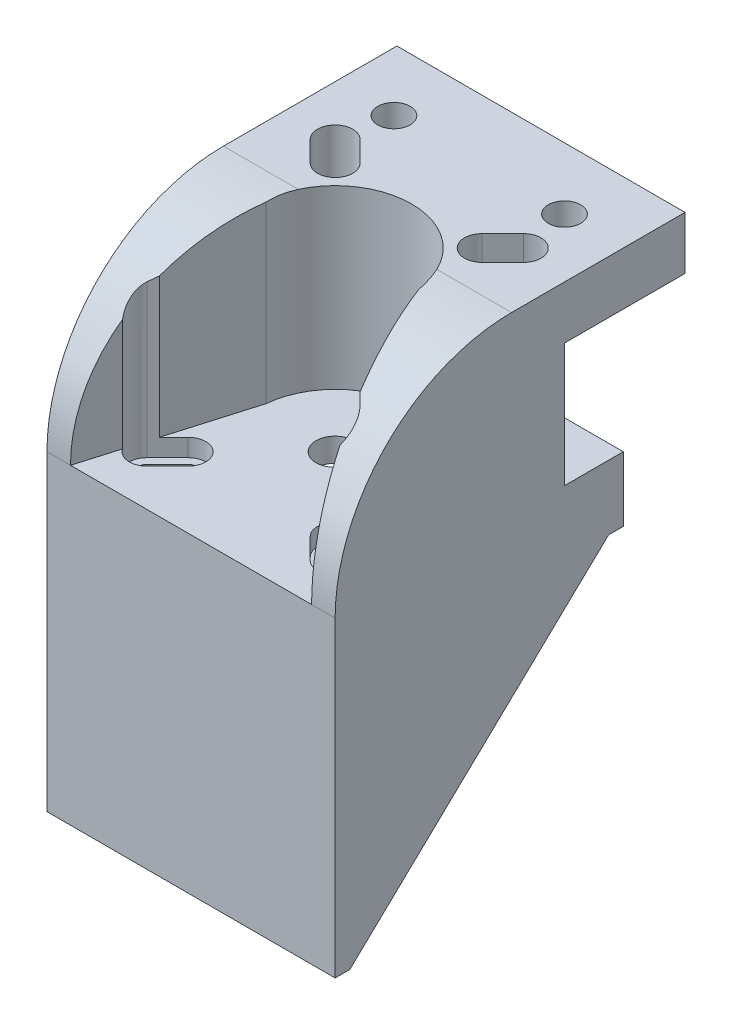
from build123d import *

# Parameters (mm, degrees)
SKETCH1_W               = 49
SKETCH1_H               = 49
SKETCH1_R               = 3.25
BOSS_EXTRUDE1_DEPTH     = 53
SKETCH2_W               = 44
SKETCH2_H               = 44
CUT_EXTRUDE1_DEPTH      = 47
SKETCH3_R               = 13
CUT_EXTRUDE2_DEPTH      = 2
CUT_EXTRUDE3_DEPTH      = 10
BOSS_EXTRUDE2_DEPTH     = 30
SKETCH7_W               = 20.5
SKETCH7_H               = 21
CUT_EXTRUDE6_DEPTH      = 59
CUT_EXTRUDE7_DEPTH      = 59
CUT_EXTRUDE7_DEPTH_BACK = 3
SKETCH10_R              = 2.75
CUT_EXTRUDE8_DEPTH      = 59
FILLET1_R               = 30
CUT_EXTRUDE9_DEPTH      = 50.0000001


with BuildPart() as part:
    # Sketch1 → Boss-Extrude1 (new body)
    with BuildSketch(Plane(origin=(0, 0, 0), x_dir=(1, 0, 0), z_dir=(0, 1, 0))):
        Rectangle(SKETCH1_W, SKETCH1_H)
        Circle(SKETCH1_R, mode=Mode.SUBTRACT)
    extrude(amount=BOSS_EXTRUDE1_DEPTH)

    # Sketch2 → Cut-Extrude1 (cut)
    with BuildSketch(Plane.XZ):
        Rectangle(SKETCH2_W, SKETCH2_H)
    extrude(amount=-CUT_EXTRUDE1_DEPTH, mode=Mode.SUBTRACT)

    # Sketch3 → Cut-Extrude2 (cut)
    with BuildSketch(Plane.XZ.offset(-47)):
        Circle(SKETCH3_R)
    extrude(amount=-CUT_EXTRUDE2_DEPTH, mode=Mode.SUBTRACT)

    # Sketch4 → Cut-Extrude3 (cut)
    with BuildSketch(Plane(origin=(0, 53, 0), x_dir=(1, 0, 0), z_dir=(0, 1, 0))):
        with BuildLine():
            Line((-14.86862915, 17.13137085), (-11.36862915, 13.63137085))
            ThreePointArc((-11.36862915, 13.63137085), (-11.36862915, 11.36862915), (-13.63137085, 11.36862915))
            Line((-13.63137085, 11.36862915), (-17.13137085, 14.86862915))
            ThreePointArc((-17.13137085, 14.86862915), (-17.13137085, 17.13137085), (-14.86862915, 17.13137085))
        make_face()
        with BuildLine():
            Line((11.36862915, 13.63137085), (14.86862915, 17.13137085))
            ThreePointArc((14.86862915, 17.13137085), (17.13137085, 17.13137085), (17.13137085, 14.86862915))
            Line((17.13137085, 14.86862915), (13.63137085, 11.36862915))
            ThreePointArc((13.63137085, 11.36862915), (11.36862915, 11.36862915), (11.36862915, 13.63137085))
        make_face()
        with BuildLine():
            Line((13.63137085, -11.36862915), (17.13137085, -14.86862915))
            ThreePointArc((17.13137085, -14.86862915), (17.13137085, -17.13137085), (14.86862915, -17.13137085))
            Line((14.86862915, -17.13137085), (11.36862915, -13.63137085))
            ThreePointArc((11.36862915, -13.63137085), (11.36862915, -11.36862915), (13.63137085, -11.36862915))
        make_face()
        with BuildLine():
            Line((-11.36862915, -13.63137085), (-14.86862915, -17.13137085))
            ThreePointArc((-14.86862915, -17.13137085), (-17.13137085, -17.13137085), (-17.13137085, -14.86862915))
            Line((-17.13137085, -14.86862915), (-13.63137085, -11.36862915))
            ThreePointArc((-13.63137085, -11.36862915), (-11.36862915, -11.36862915), (-11.36862915, -13.63137085))
        make_face()
    extrude(amount=-CUT_EXTRUDE3_DEPTH, mode=Mode.SUBTRACT)

    # Sketch5 → Boss-Extrude2 (add)
    with BuildSketch(Plane(origin=(0, 53, 0), x_dir=(1, 0, 0), z_dir=(0, 1, 0))):
        with BuildLine():
            Line((-20.5, -24.5), (-12.942531675, 1.221013453))
            ThreePointArc((-12.942531675, 1.221013453), (-8.750052146, 9.614394804), (0, 13))
            ThreePointArc((0, 13), (8.750052146, 9.614394804), (12.942531675, 1.221013453))
            Line((12.942531675, 1.221013453), (20.5, -24.5))
            Line((20.5, -24.5), (24.5, -24.5))
            Line((24.5, -24.5), (24.5, 35))
            Line((24.5, 35), (-24.5, 35))
            Line((-24.5, 35), (-24.5, -24.5))
            Line((-24.5, -24.5), (-20.5, -24.5))
        make_face()
    extrude(amount=BOSS_EXTRUDE2_DEPTH)

    # Sketch7 → Cut-Extrude6 (cut)
    with BuildSketch(Plane.ZY.offset(24.5)):
        with Locations((-24.75, 63.5)):
            Rectangle(SKETCH7_W, SKETCH7_H)
    extrude(amount=-CUT_EXTRUDE6_DEPTH, mode=Mode.SUBTRACT)

    # Sketch9 → Cut-Extrude7 (cut, two sides)
    with BuildSketch(Plane(origin=(0, 53, 0), x_dir=(1, 0, 0), z_dir=(0, 1, 0))) as cut_extrude7_sk:
        with BuildLine():
            Line((-14.621320344, 10.378679656), (-18.121320344, 13.878679656))
            ThreePointArc((-18.121320344, 13.878679656), (-18.121320344, 18.121320344), (-13.878679656, 18.121320344))
            Line((-13.878679656, 18.121320344), (-10.378679656, 14.621320344))
            ThreePointArc((-10.378679656, 14.621320344), (-10.378679656, 10.378679656), (-14.621320344, 10.378679656))
        make_face()
        with BuildLine():
            Line((10.378679656, 14.621320344), (13.878679656, 18.121320344))
            ThreePointArc((13.878679656, 18.121320344), (18.121320344, 18.121320344), (18.121320344, 13.878679656))
            Line((18.121320344, 13.878679656), (14.621320344, 10.378679656))
            ThreePointArc((14.621320344, 10.378679656), (10.378679656, 10.378679656), (10.378679656, 14.621320344))
        make_face()
        with BuildLine():
            Line((13.878679656, -18.121320344), (10.378679656, -14.621320344))
            ThreePointArc((10.378679656, -14.621320344), (10.378679656, -10.378679656), (14.621320344, -10.378679656))
            Line((14.621320344, -10.378679656), (18.121320344, -13.878679656))
            ThreePointArc((18.121320344, -13.878679656), (18.121320344, -18.121320344), (13.878679656, -18.121320344))
        make_face()
        with BuildLine():
            Line((-13.878679656, -18.121320344), (-10.378679656, -14.621320344))
            ThreePointArc((-10.378679656, -14.621320344), (-10.378679656, -10.378679656), (-14.621320344, -10.378679656))
            Line((-14.621320344, -10.378679656), (-18.121320344, -13.878679656))
            ThreePointArc((-18.121320344, -13.878679656), (-18.121320344, -18.121320344), (-13.878679656, -18.121320344))
        make_face()
    extrude(amount=CUT_EXTRUDE7_DEPTH, mode=Mode.SUBTRACT)
    extrude(cut_extrude7_sk.sketch, amount=-CUT_EXTRUDE7_DEPTH_BACK, mode=Mode.SUBTRACT)

    # Sketch10 → Cut-Extrude8 (cut)
    with BuildSketch(Plane.XZ.offset(-74)):
        with Locations((14.5, -24.5)):
            Circle(SKETCH10_R)
        with Locations((-14.5, -24.5)):
            Circle(SKETCH10_R)
    extrude(amount=-CUT_EXTRUDE8_DEPTH, mode=Mode.SUBTRACT)

    # Fillet1
    fillet1_edges = [part.edges().sort_by_distance(p)[0] for p in [
        (22.5, 83, 24.5),
        (-22.5, 83, 24.5),
    ]]
    fillet(fillet1_edges, radius=FILLET1_R)

    # Sketch11 → Cut-Extrude9 (cut, through all)
    with BuildSketch(Plane(origin=(24.5, 0, 0), x_dir=(0, 0, -1), z_dir=(1, 0, 0))):
        Polygon((24.5, 0), (24.5, 42), (22, 42), (-22, 0), align=None)
    extrude(amount=-CUT_EXTRUDE9_DEPTH, mode=Mode.SUBTRACT)


solid = part.part
